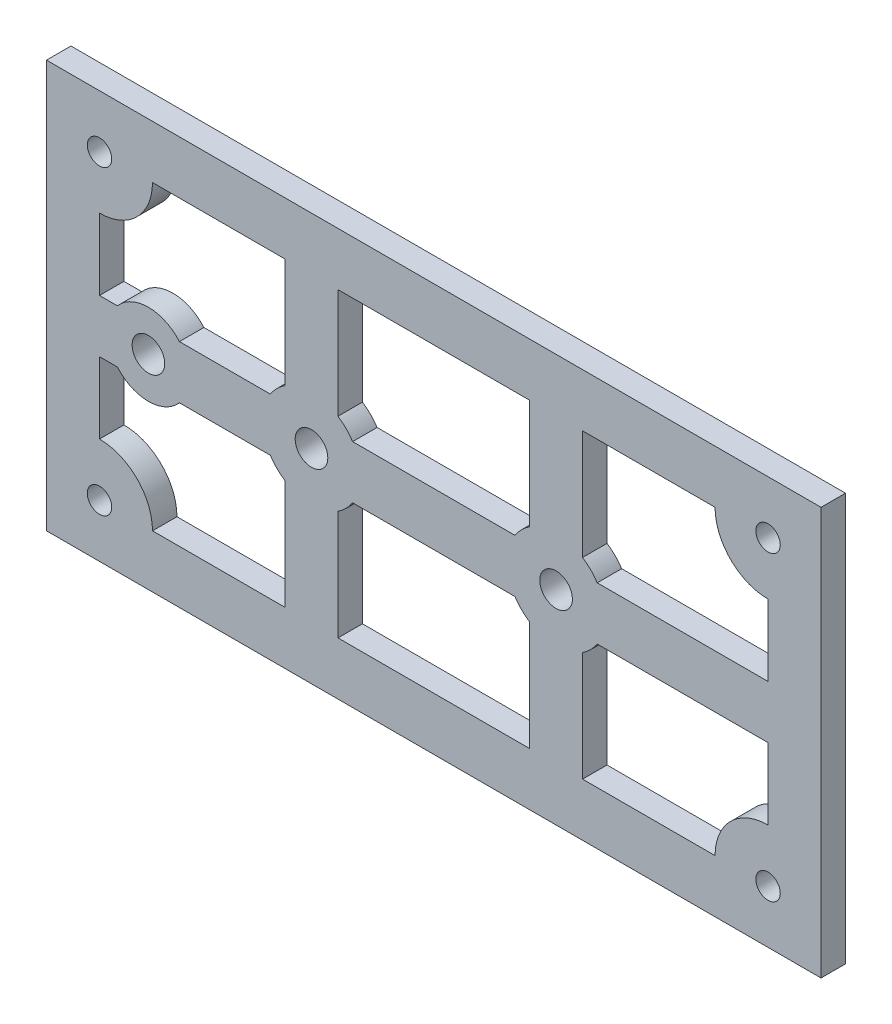
from build123d import *

# Parameters (mm, degrees)
SKETCH1_W           = 95
SKETCH1_H           = 50
BOSS_EXTRUDE1_DEPTH = 3
SKETCH4_R           = 2
CUT_EXTRUDE3_DEPTH  = 4
SKETCH5_R           = 1.5
CUT_EXTRUDE4_DEPTH  = 4


with BuildPart() as part:
    # Sketch1 → Boss-Extrude1 (new body)
    with BuildSketch(Plane.XY):
        Rectangle(SKETCH1_W, SKETCH1_H)
    extrude(amount=BOSS_EXTRUDE1_DEPTH)

    # Sketch4 → Cut-Extrude3 (cut, through all)
    with BuildSketch(Plane.XY.offset(3)):
        with Locations((-15, 0)):
            Circle(SKETCH4_R)
        with Locations((15, 0)):
            Circle(SKETCH4_R)
        with Locations((-35, 0)):
            Circle(SKETCH4_R)
    extrude(amount=-CUT_EXTRUDE3_DEPTH, mode=Mode.SUBTRACT)

    # Sketch5 → Cut-Extrude4 (cut, through all)
    with BuildSketch(Plane.XY.offset(3)):
        with Locations((41, 18.5)):
            Circle(SKETCH5_R)
        with Locations((-41, 18.5)):
            Circle(SKETCH5_R)
        with BuildLine():
            Line((-34.5, 18.5), (-18.25, 18.5))
            Line((-18.25, 18.5), (-18.25, 5.04356025))
            ThreePointArc((-18.25, 5.04356025), (-19.242640687, 4.242640687), (-20.04356025, 3.25))
            Line((-20.04356025, 3.25), (-31.200328962, 3.25))
            ThreePointArc((-31.200328962, 3.25), (-35, 5), (-38.799671038, 3.25))
            Line((-38.799671038, 3.25), (-41, 3.25))
            Line((-41, 3.25), (-41, 12))
            ThreePointArc((-41, 12), (-36.403805922, 13.903805922), (-34.5, 18.5))
        make_face()
        with BuildLine():
            Line((-11.75, 5.04356025), (-11.75, 18.5))
            Line((-11.75, 18.5), (11.75, 18.5))
            Line((11.75, 18.5), (11.75, 5.04356025))
            ThreePointArc((11.75, 5.04356025), (10.757359313, 4.242640687), (9.95643975, 3.25))
            Line((9.95643975, 3.25), (-9.95643975, 3.25))
            ThreePointArc((-9.95643975, 3.25), (-10.757359313, 4.242640687), (-11.75, 5.04356025))
        make_face()
        with BuildLine():
            Line((18.25, 5.04356025), (18.25, 18.5))
            Line((18.25, 18.5), (34.5, 18.5))
            ThreePointArc((34.5, 18.5), (36.403805922, 13.903805922), (41, 12))
            Line((41, 12), (41, 3.25))
            Line((41, 3.25), (20.04356025, 3.25))
            ThreePointArc((20.04356025, 3.25), (19.242640687, 4.242640687), (18.25, 5.04356025))
        make_face()
    cut_extrude4 = extrude(amount=-CUT_EXTRUDE4_DEPTH, mode=Mode.SUBTRACT)

    # Mirror2: Cut-Extrude4 across plane
    add(cut_extrude4.mirror(Plane.ZX), mode=Mode.SUBTRACT)


solid = part.part
